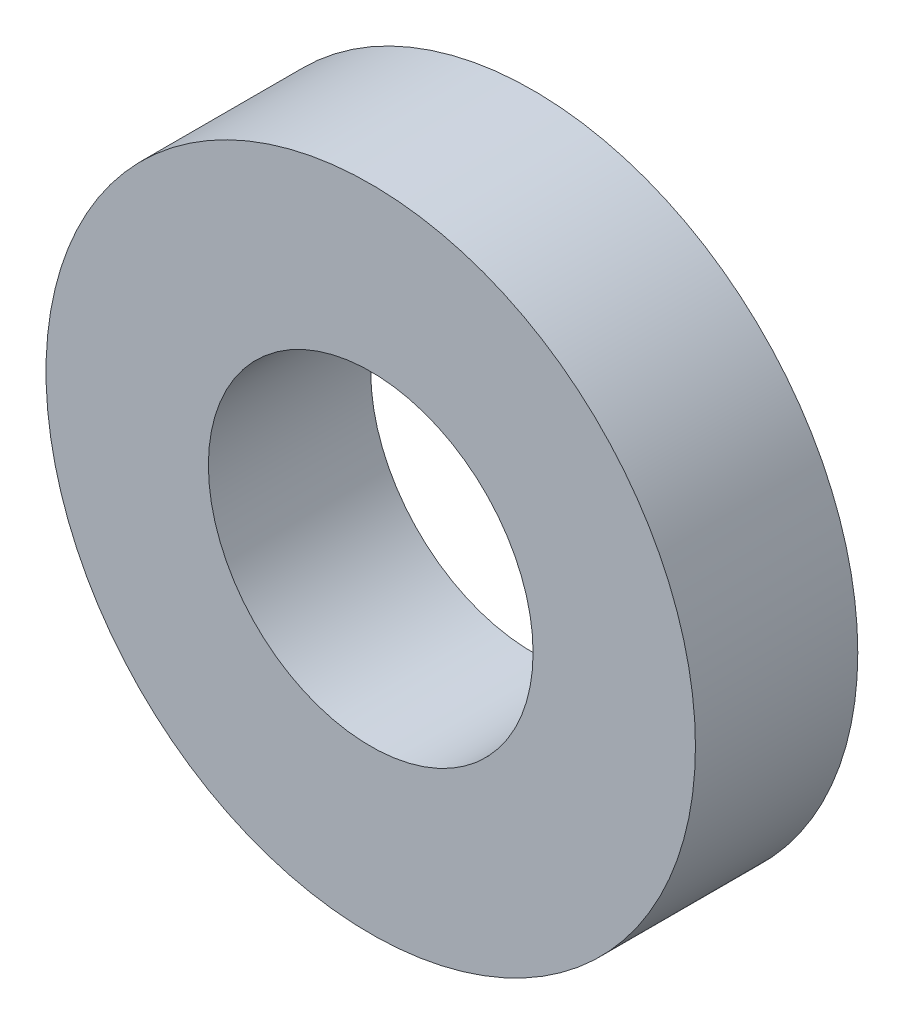
from build123d import *

# Parameters (mm, degrees)
SKETCH_1_R      = 20
SKETCH_1_R_2    = 10
EXTRUDE_1_DEPTH = 10


with BuildPart() as part:
    # 草图1 → 凸台-拉伸1 (new body)
    with BuildSketch(Plane.XY):
        Circle(SKETCH_1_R)
        Circle(SKETCH_1_R_2, mode=Mode.SUBTRACT)
    extrude(amount=EXTRUDE_1_DEPTH)


solid = part.part
